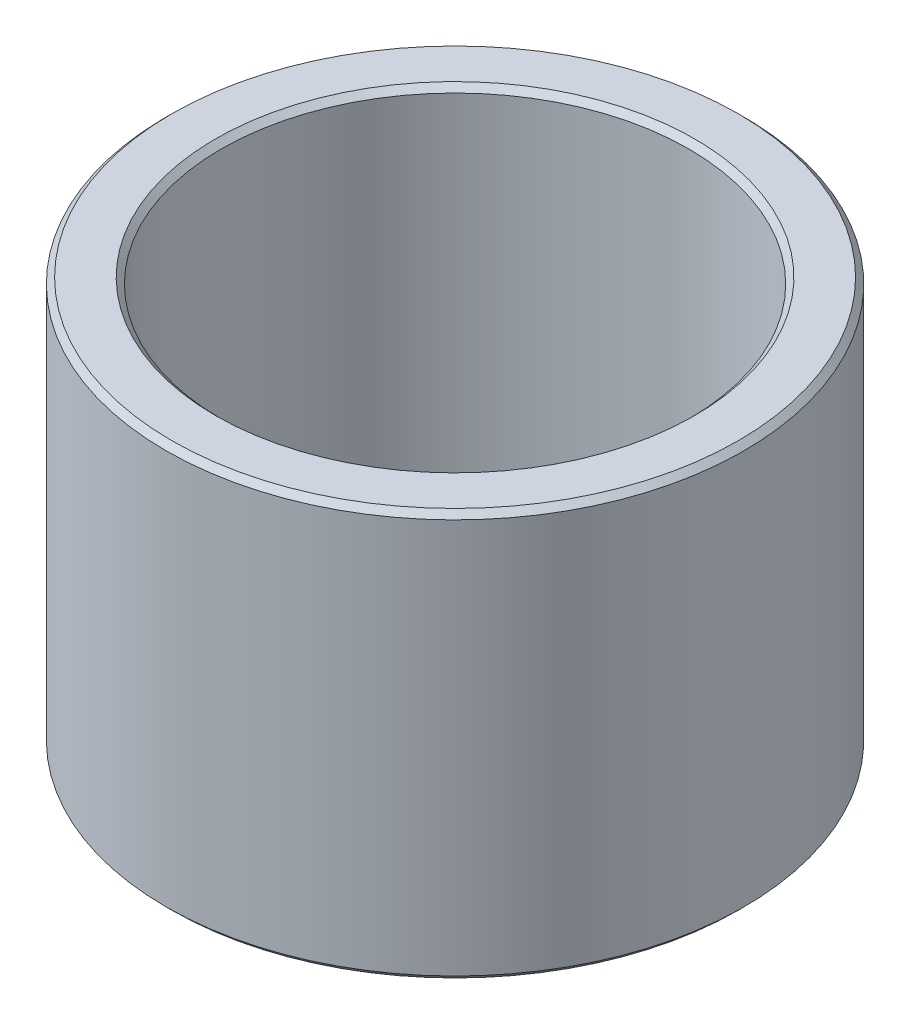
from build123d import *

# Parameters (mm, degrees)
SKETCH1_R           = 4.975
SKETCH1_R_2         = 4.025
BOSS_EXTRUDE1_DEPTH = 3.5
CHAMFER1_SIZE       = 0.1


with BuildPart() as part:
    # Sketch1 → Boss-Extrude1 (new body, symmetric)
    with BuildSketch(Plane(origin=(0, 0, 0), x_dir=(1, 0, 0), z_dir=(0, 1, 0))):
        Circle(SKETCH1_R)
        Circle(SKETCH1_R_2, mode=Mode.SUBTRACT)
    extrude(amount=BOSS_EXTRUDE1_DEPTH, both=True)

    # Chamfer1
    chamfer1_edges = [part.edges().sort_by_distance(p)[0] for p in [
        (-4.975, -3.5, 0),
        (-4.975, 3.5, 0),
        (-4.025, -3.5, 0),
        (-4.025, 3.5, 0),
    ]]
    chamfer(chamfer1_edges, length=CHAMFER1_SIZE)


solid = part.part
